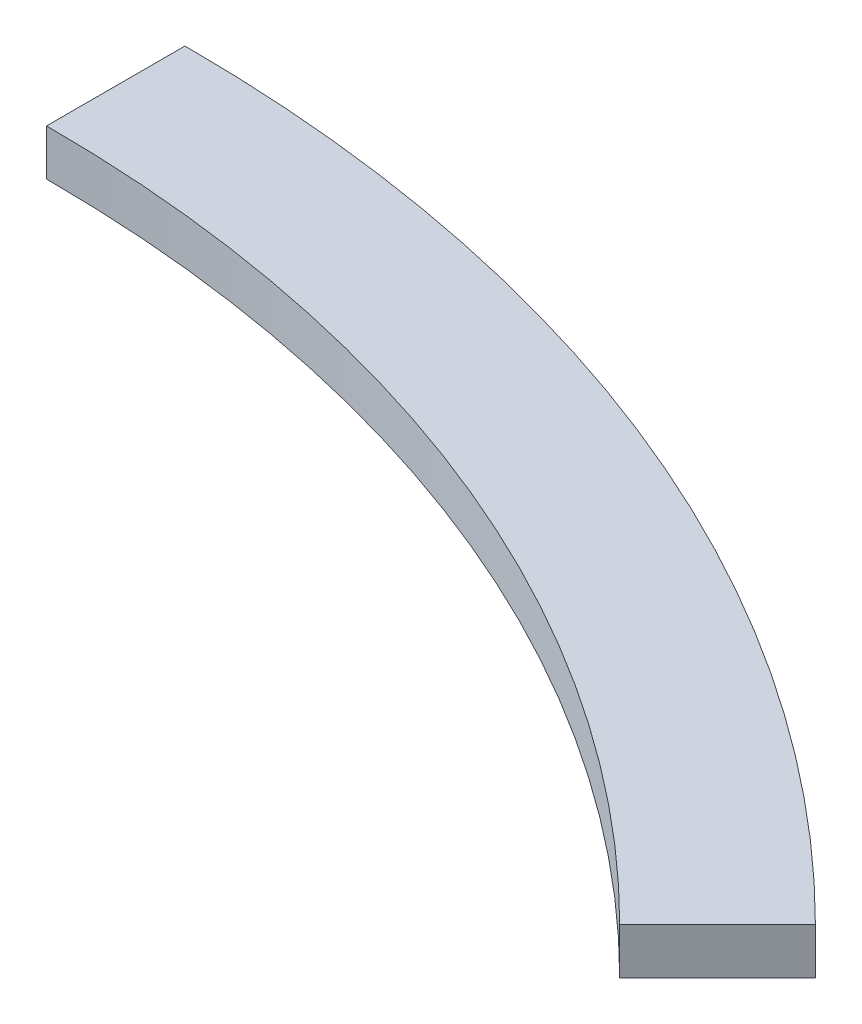
from build123d import *

# Parameters (mm, degrees)
BOSS_EXTRUDE1_DEPTH = 10


with BuildPart() as part:
    # Sketch1 → Boss-Extrude1 (new body)
    with BuildSketch(Plane(origin=(0, 0, 0), x_dir=(1, 0, 0), z_dir=(0, 1, 0))):
        with BuildLine():
            ThreePointArc((0, 330), (126.28553268, 304.880245729), (233.345237792, 233.345237792))
            Line((233.345237792, 233.345237792), (212.132034356, 212.132034356))
            ThreePointArc((212.132034356, 212.132034356), (114.80502971, 277.163859753), (0, 300))
            Line((0, 300), (0, 330))
        make_face()
    extrude(amount=BOSS_EXTRUDE1_DEPTH)


solid = part.part
